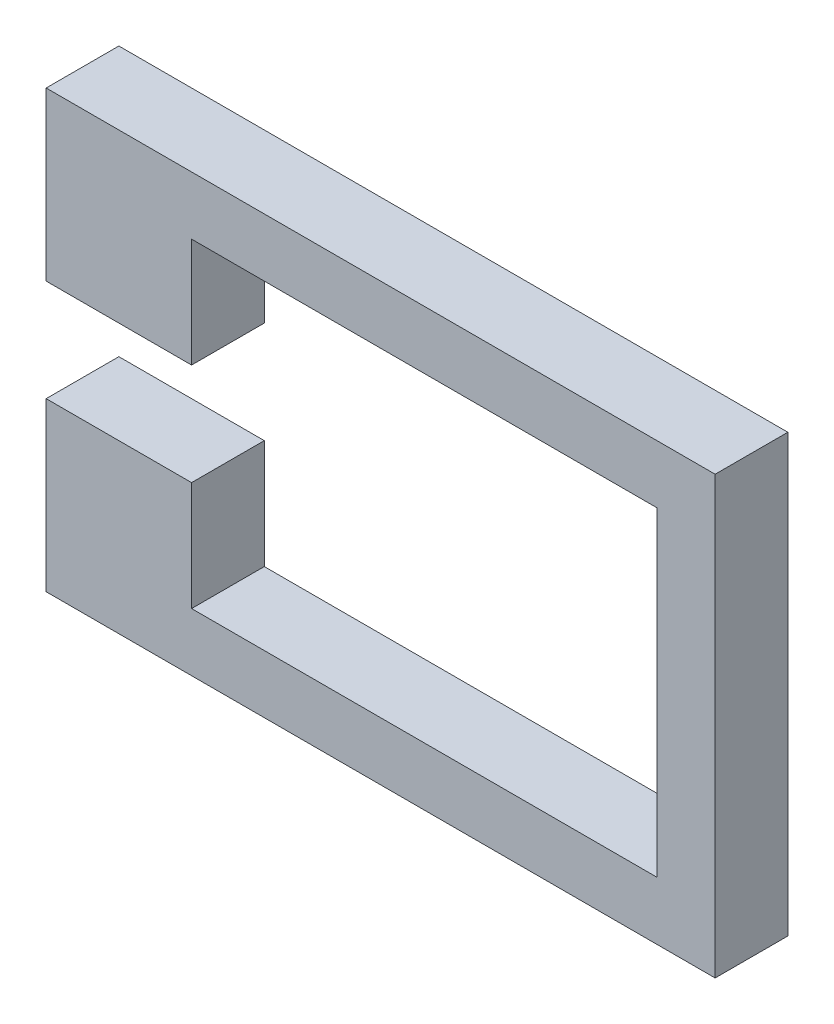
from build123d import *

# Parameters (mm, degrees)
BOSS_EXTRUDE1_DEPTH = 6.35


with BuildPart() as part:
    # Sketch1 → Boss-Extrude1 (new body)
    with BuildSketch(Plane.XY):
        Polygon((-13.97, -8.255), (-26.67, -8.255), (-26.67, 6.35), (31.75, 6.35), (31.75, -31.75), (-26.67, -31.75), (-26.67, -17.145), (-13.97, -17.145), (-13.97, -26.67), (26.67, -26.67), (26.67, 1.27), (-13.97, 1.27), align=None)
    extrude(amount=BOSS_EXTRUDE1_DEPTH)


solid = part.part
